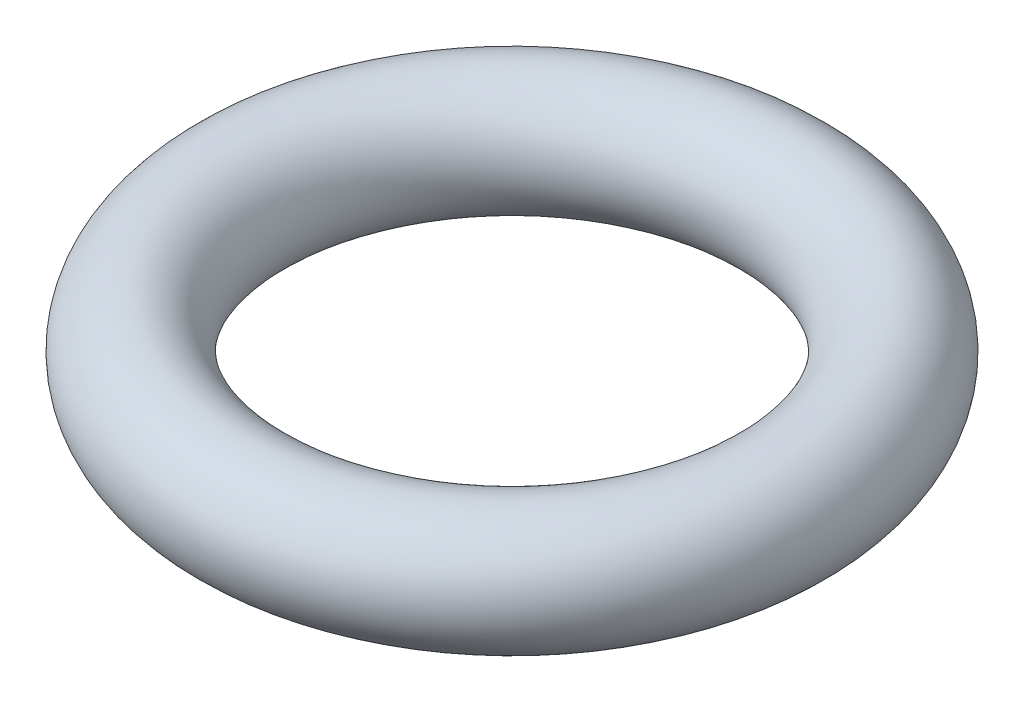
from build123d import *

# Parameters (mm, degrees)
SKETCH1_R = 1


with BuildPart() as part:
    # Sketch1 → Revolve1 (revolve)
    with BuildSketch(Plane.XY):
        with Locations((-4.5, 0)):
            Circle(SKETCH1_R)
    revolve(axis=Axis((0, 0, 0), (0, 1, 0)))


solid = part.part
